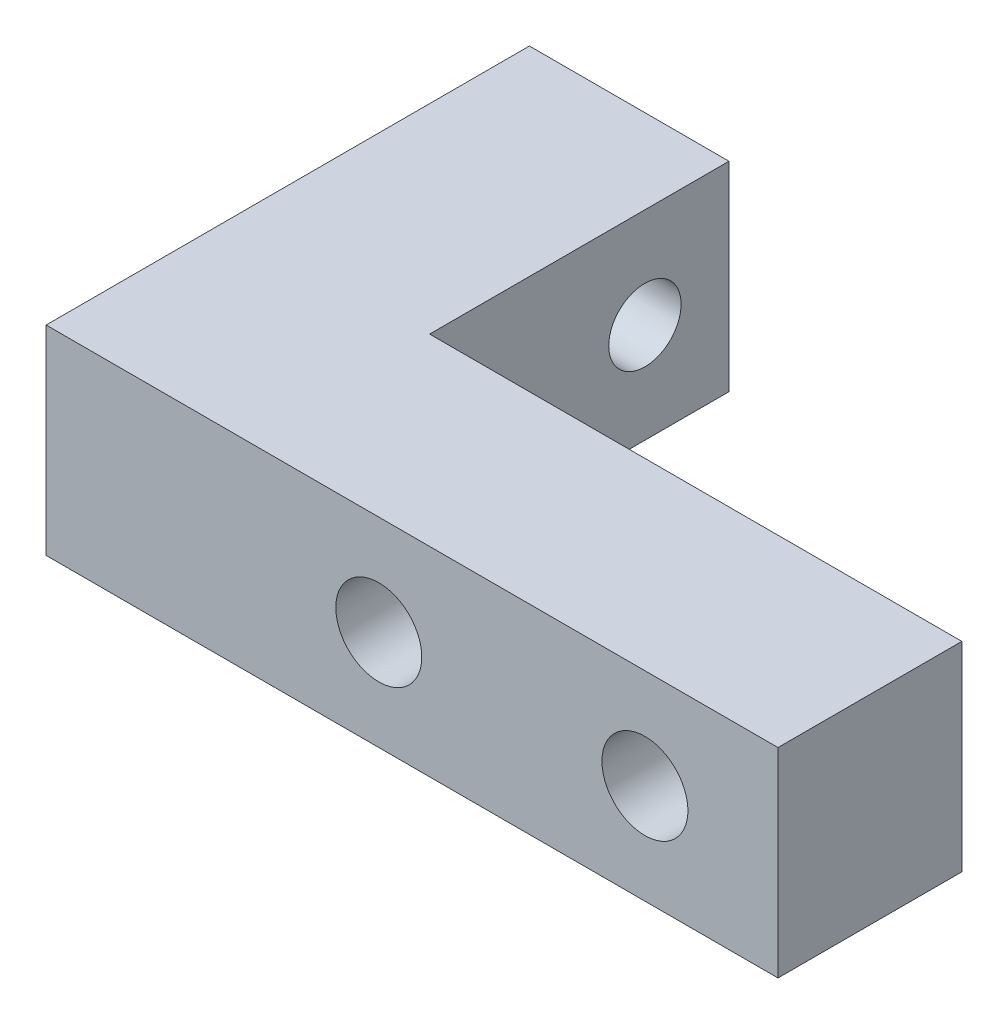
from build123d import *

# Parameters (mm, degrees)
SKETCH1_W                          = 69.85
SKETCH1_H                          = 47.625
BOSS_EXTRUDE1_DEPTH                = 19.05
CUT_EXTRUDE1_REACH                 = 21.05
SKETCH2_W                          = 50.8
SKETCH2_H                          = 28.575
F_5_16_24_TAPPED_HOLE1_D           = 6.9088
F_5_16_24_TAPPED_HOLE1_DEPTH       = 19.06
F_5_16_24_TAPPED_HOLE1_CSINK_D     = 9.2075
F_5_16_24_TAPPED_HOLE1_CSINK_ANGLE = 90
F_5_16_24_TAPPED_HOLE1_TIP         = 2.075612922
F_5_16_CLEARANCE_HOLE1_D           = 8.2042
F_5_16_CLEARANCE_HOLE1_CSINK_D     = 9.4742
F_5_16_CLEARANCE_HOLE1_CSINK_ANGLE = 90
CHAMFER1_SIZE                      = 1.5


with BuildPart() as part:
    # Sketch1 → Boss-Extrude1 (new body)
    with BuildSketch(Plane(origin=(0, 0, 0), x_dir=(1, 0, 0), z_dir=(0, 1, 0))):
        Rectangle(SKETCH1_W, SKETCH1_H)
    extrude(amount=BOSS_EXTRUDE1_DEPTH)

    # Sketch2 → Cut-Extrude1 (cut, up to next)
    with BuildSketch(Plane(origin=(0, 19.05, 0), x_dir=(1, 0, 0), z_dir=(0, 1, 0)), mode=Mode.PRIVATE) as cut_extrude1_sk1:
        with Locations((9.525, 9.525)):
            Rectangle(SKETCH2_W, SKETCH2_H)
    cut_extrude1_tool1 = extrude(cut_extrude1_sk1.sketch, amount=-CUT_EXTRUDE1_REACH, mode=Mode.PRIVATE) & part.part
    add(cut_extrude1_tool1.solids().sort_by_distance((9.525, 19.05, -9.525))[0], mode=Mode.SUBTRACT)

    # 5/16-24 Tapped Hole1
    with Locations(Plane.ZY.offset(34.925)):
        with Locations((-14.2875, 9.525), (11.1125, 9.525)):
            CounterSinkHole(F_5_16_24_TAPPED_HOLE1_D / 2, F_5_16_24_TAPPED_HOLE1_CSINK_D / 2, depth=F_5_16_24_TAPPED_HOLE1_DEPTH, counter_sink_angle=F_5_16_24_TAPPED_HOLE1_CSINK_ANGLE)
            with Locations((0, 0, -(F_5_16_24_TAPPED_HOLE1_DEPTH + F_5_16_24_TAPPED_HOLE1_TIP / 2))):  # 118° drill point
                Cone(0, F_5_16_24_TAPPED_HOLE1_D / 2, F_5_16_24_TAPPED_HOLE1_TIP, mode=Mode.SUBTRACT)

    # 5/16 Clearance Hole1 (through all)
    with Locations(Plane(origin=(0, 0, 4.7625), x_dir=(-1, 0, 0), z_dir=(0, 0, -1))):
        with Locations((3.175, 9.525), (-22.225, 9.525)):
            CounterSinkHole(F_5_16_CLEARANCE_HOLE1_D / 2, F_5_16_CLEARANCE_HOLE1_CSINK_D / 2, counter_sink_angle=F_5_16_CLEARANCE_HOLE1_CSINK_ANGLE)

    # Chamfer1
    chamfer1_edges = [part.edges().sort_by_distance(p)[0] for p in [
        (-25.4, 0, -23.8125),
        (-25.4, 19.05, -23.8125),
        (9.525, 0, 4.7625),
        (34.925, 9.525, 4.7625),
        (-15.875, 9.525, -23.8125),
        (9.525, 19.05, 4.7625),
    ]]
    chamfer(chamfer1_edges, length=CHAMFER1_SIZE)


solid = part.part
